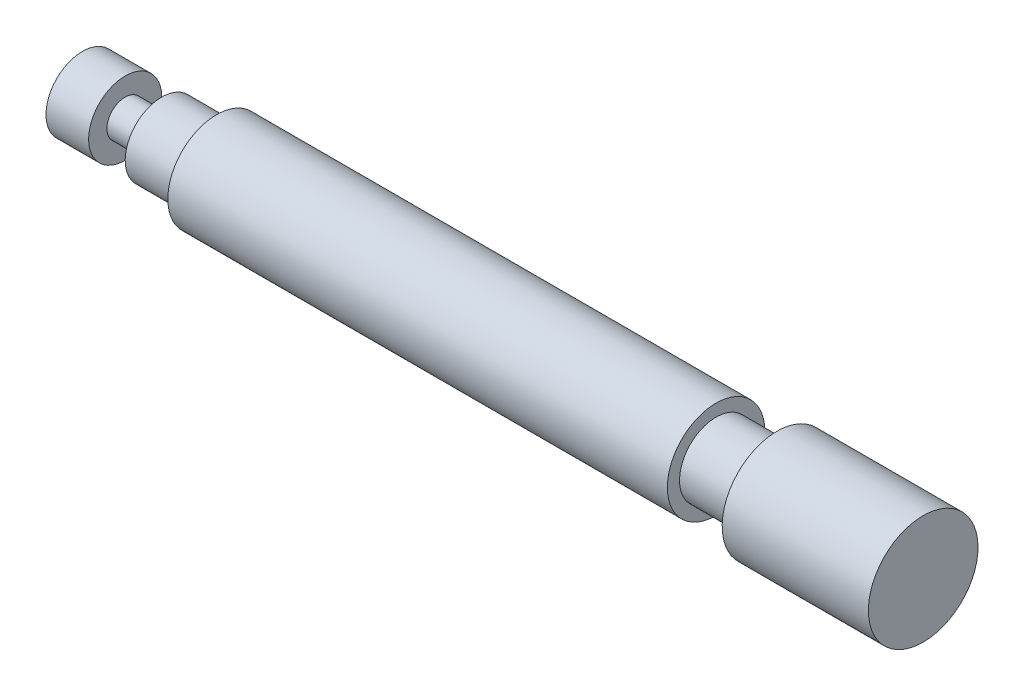
from build123d import *


with BuildPart() as part:
    # Sketch1 → Revolve1 (revolve)
    with BuildSketch(Plane.XY):
        Polygon((-69, 0), (69, 0), (69, 9), (45, 9), (45, 6), (35, 6), (35, 8), (-47, 8), (-47, 6), (-56, 6), (-56, 3), (-62, 3), (-62, 6), (-69, 6), align=None)
    revolve(axis=Axis((-69, 0, 0), (1, 0, 0)))


solid = part.part
